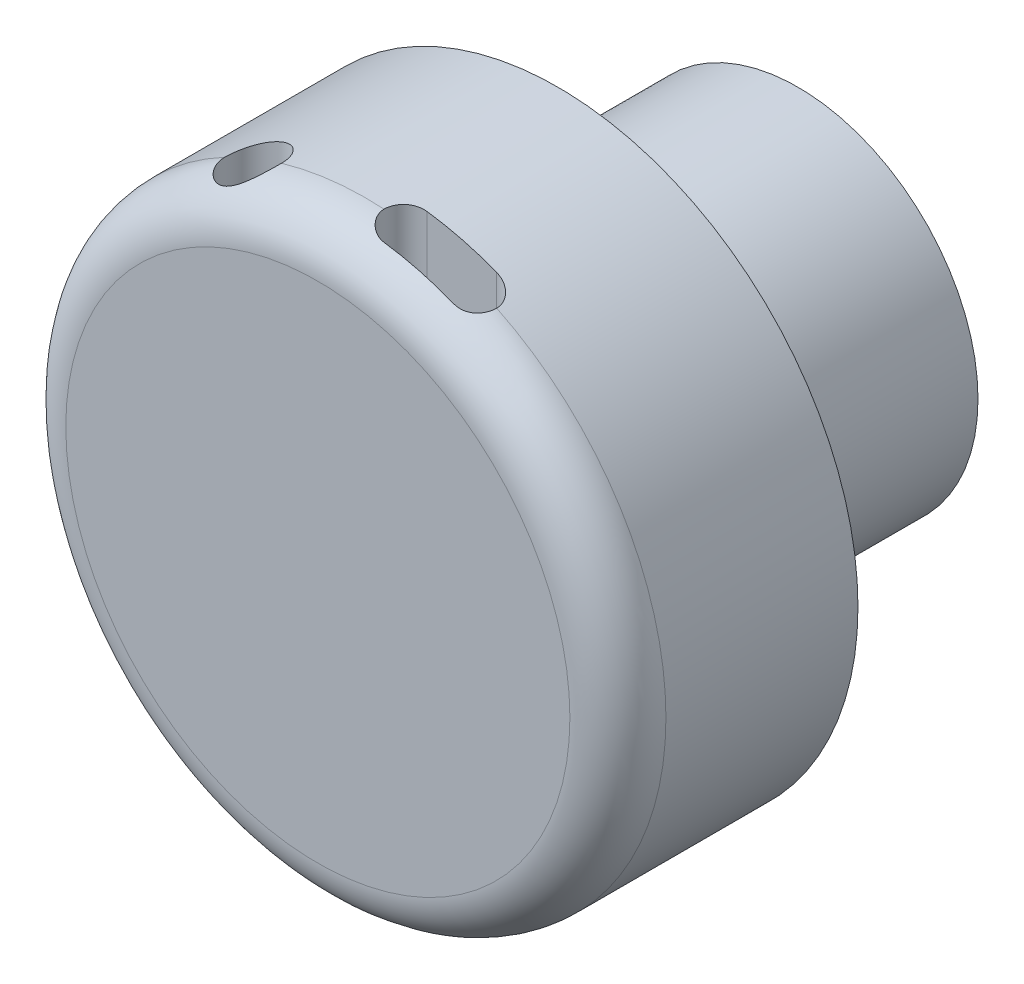
from build123d import *

# Parameters (mm, degrees)
SKETCH1_R               = 125
BOSS_EXTRUDE1_DEPTH     = 100
FILLET1_R               = 20
SKETCH2_R               = 11.805832703
CUT_EXTRUDE1_DEPTH      = 126
CUT_EXTRUDE1_DEPTH_BACK = 126
SKETCH3_R               = 75
BOSS_EXTRUDE2_DEPTH     = 100
CHAMFER1_SIZE           = 28.26
CHAMFER1_SIZE2          = 16.980321094


with BuildPart() as part:
    # Sketch1 → Boss-Extrude1 (new body)
    with BuildSketch(Plane.XY):
        Circle(SKETCH1_R)
    extrude(amount=BOSS_EXTRUDE1_DEPTH)

    # Fillet1
    fillet1_edges = [part.edges().sort_by_distance(p)[0] for p in [
        (-125, 0, 100),
    ]]
    fillet(fillet1_edges, radius=FILLET1_R)

    # Sketch2 → Cut-Extrude1 (cut, two sides)
    with BuildSketch(Plane(origin=(0, 0, 0), x_dir=(1, 0, 0), z_dir=(0, 1, 0))) as cut_extrude1_sk:
        with Locations((-46.950776643, -80)):
            Circle(SKETCH2_R)
        with BuildLine():
            Line((16.547286213, -71.022688997), (45.520734854, -71.022688997))
            ThreePointArc((45.520734854, -71.022688997), (54.498045857, -80), (45.520734854, -88.977311003))
            Line((45.520734854, -88.977311003), (16.547286213, -88.977311003))
            ThreePointArc((16.547286213, -88.977311003), (7.56997521, -80), (16.547286213, -71.022688997))
        make_face()
    extrude(amount=CUT_EXTRUDE1_DEPTH, mode=Mode.SUBTRACT)
    extrude(cut_extrude1_sk.sketch, amount=-CUT_EXTRUDE1_DEPTH_BACK, mode=Mode.SUBTRACT)

    # Sketch3 → Boss-Extrude2 (add)
    with BuildSketch(Plane(origin=(0, 0, 0), x_dir=(-1, 0, 0), z_dir=(0, 0, -1))):
        Circle(SKETCH3_R)
    extrude(amount=BOSS_EXTRUDE2_DEPTH)

    # Chamfer1
    chamfer1_edges = [part.edges().sort_by_distance(p)[0] for p in [
        (75, 0, 0),
    ]]
    chamfer1_side = [part.faces().sort_by_distance(p)[0] for p in [
        (-121.464466094, 0, 0),
    ]]
    chamfer(chamfer1_edges, length=CHAMFER1_SIZE, length2=CHAMFER1_SIZE2, reference=chamfer1_side[0])


solid = part.part
